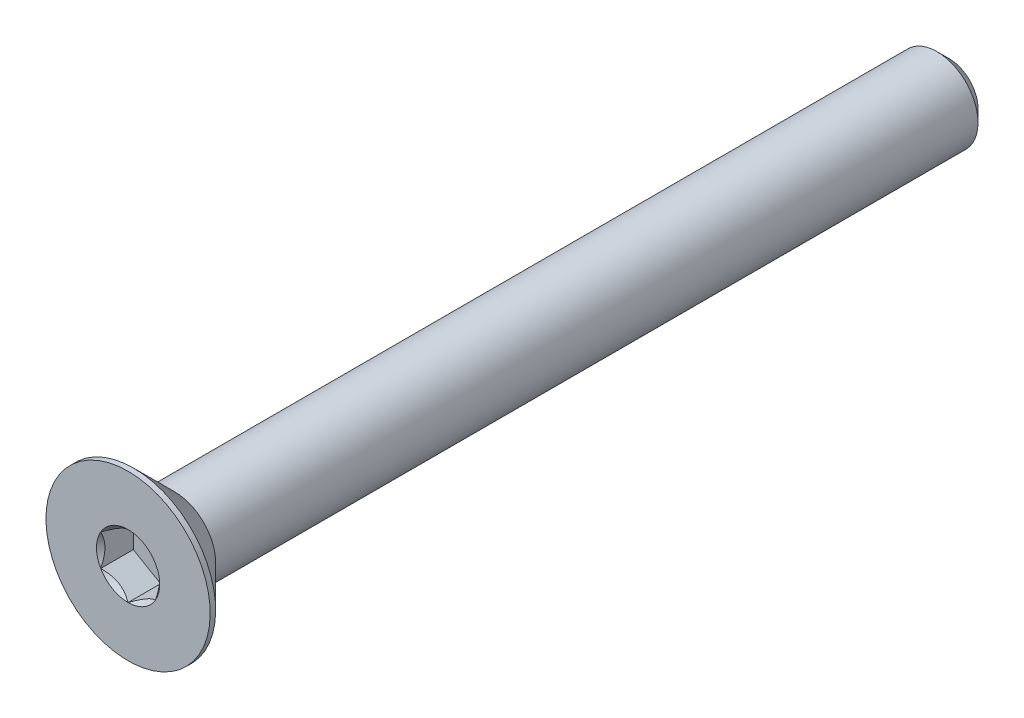
from build123d import *

# Parameters (mm, degrees)
SKETCH3_W          = 30
SKETCH3_H          = 1.5
CHAMFER1_SIZE      = 0.45
CUT_EXTRUDE1_DEPTH = 1.19


with BuildPart() as part:
    # Sketch3 → Revolve1 (revolve)
    with BuildSketch(Plane(origin=(0, 0, 0), x_dir=(0, 0, -1), z_dir=(1, 0, 0))):
        with Locations((0, 0.75)):
            Rectangle(SKETCH3_W, SKETCH3_H)
    revolve(axis=Axis((0, 0, -15), (0, 0, 1)))

    # Chamfer1
    chamfer1_edges = [part.edges().sort_by_distance(p)[0] for p in [
        (0, -1.5, -15),
    ]]
    chamfer(chamfer1_edges, length=CHAMFER1_SIZE)

    # Sketch6 → Revolve2 (revolve)
    with BuildSketch(Plane(origin=(0, 0, 0), x_dir=(0, 0, -1), z_dir=(1, 0, 0))):
        Polygon((-15, 3), (-14.8, 3), (-13.3, 1.5), (-13.3, 0), (-15, 0), align=None)
    revolve(axis=Axis((0, 0, -15), (0, 0, 1)))

    # Sketch8 → Cut-Extrude1 (cut)
    with BuildSketch(Plane.XY.offset(15)):
        Polygon((0, 1.154700538), (-1, 0.577350269), (-1, -0.577350269), (0, -1.154700538), (1, -0.577350269), (1, 0.577350269), align=None)
    extrude(amount=-CUT_EXTRUDE1_DEPTH, mode=Mode.SUBTRACT)

    # Cut-Extrude2 cone 1 section (through the dimple's axis) → Cut-Extrude2 (revolve, cut)
    with BuildSketch(Plane(origin=(0, 0, 15), x_dir=(0, -1, 0), z_dir=(1, 0, 0))):
        Polygon((0, 0), (1.154700538, 0), (0, 1.154700538), align=None)
    revolve(axis=Axis((0, 0, 15), (0, 0, -1)), mode=Mode.SUBTRACT)


solid = part.part
